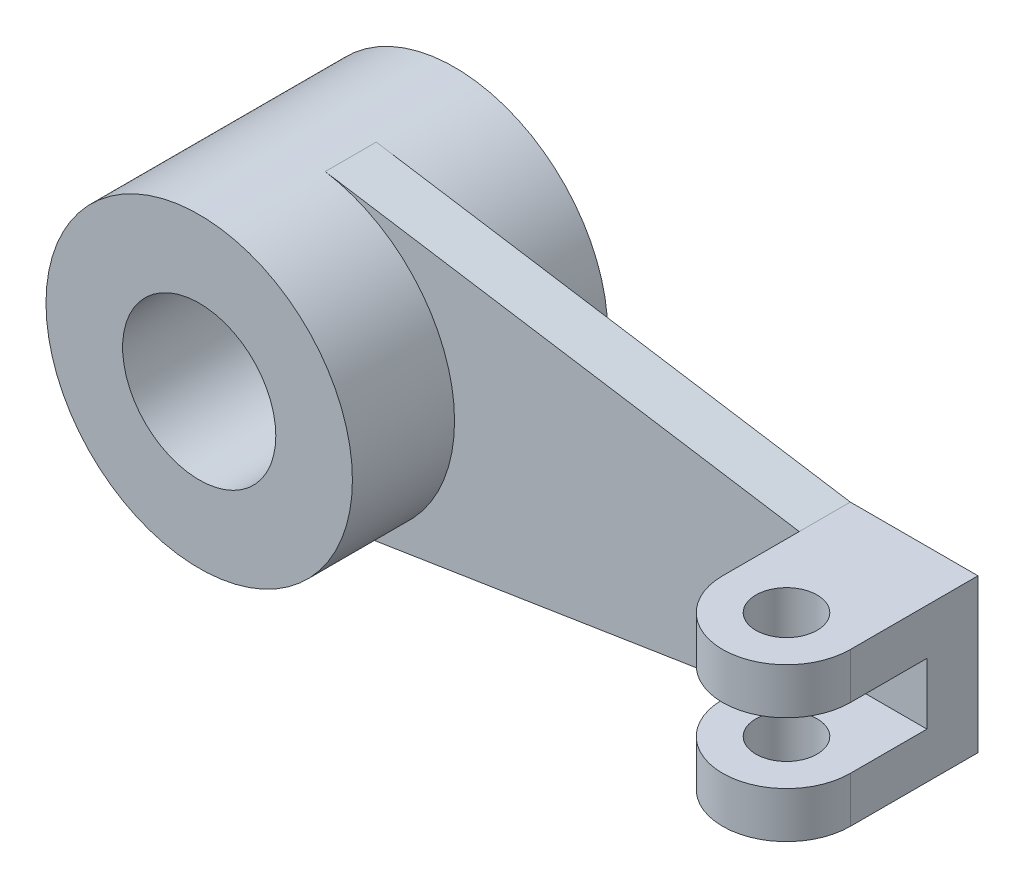
from build123d import *

# Parameters (mm, degrees)
SKETCH1_R           = 300
SKETCH1_R_2         = 150
BOSS_EXTRUDE1_DEPTH = 250
BOSS_EXTRUDE2_DEPTH = 50
SKETCH3_R           = 60
BOSS_EXTRUDE3_DEPTH = 90
SKETCH4_R           = 60
BOSS_EXTRUDE4_DEPTH = 90


with BuildPart() as part:
    # Sketch1 → Boss-Extrude1 (new body, symmetric)
    with BuildSketch(Plane.XY):
        Circle(SKETCH1_R)
        Circle(SKETCH1_R_2, mode=Mode.SUBTRACT)
    extrude(amount=BOSS_EXTRUDE1_DEPTH, both=True)

    # Sketch2 → Boss-Extrude2 (add, symmetric)
    with BuildSketch(Plane.XY):
        with BuildLine():
            Line((46.716887563, 296.340230844), (975, 150))
            Line((975, 150), (1225, 150))
            Line((1225, 150), (1225, -150))
            Line((1225, -150), (975, -150))
            Line((975, -150), (46.716887563, -296.340230844))
            ThreePointArc((46.716887563, -296.340230844), (300, 0), (46.716887563, 296.340230844))
        make_face()
    extrude(amount=BOSS_EXTRUDE2_DEPTH, both=True)

    # Sketch3 → Boss-Extrude3 (add)
    with BuildSketch(Plane.XZ.offset(150)):
        with BuildLine():
            Line((975, 50), (975, 200))
            ThreePointArc((975, 200), (1100, 325), (1225, 200))
            Line((1225, 200), (1225, 50))
            Line((1225, 50), (975, 50))
        make_face()
        with Locations(Location((1100, 200, 0), (0, 0, 270))):  # turned: the seam where the file's is
            Circle(SKETCH3_R, mode=Mode.SUBTRACT)
    extrude(amount=-BOSS_EXTRUDE3_DEPTH)

    # Sketch4 → Boss-Extrude4 (add)
    with BuildSketch(Plane(origin=(0, 150, 0), x_dir=(1, 0, 0), z_dir=(0, 1, 0))):
        with BuildLine():
            Line((975, -200), (975, -50))
            Line((975, -50), (1225, -50))
            Line((1225, -50), (1225, -200))
            ThreePointArc((1225, -200), (1100, -325), (975, -200))
        make_face()
        with Locations(Location((1100, -200, 0), (0, 0, 90))):  # turned: the seam where the file's is
            Circle(SKETCH4_R, mode=Mode.SUBTRACT)
    extrude(amount=-BOSS_EXTRUDE4_DEPTH)


solid = part.part
